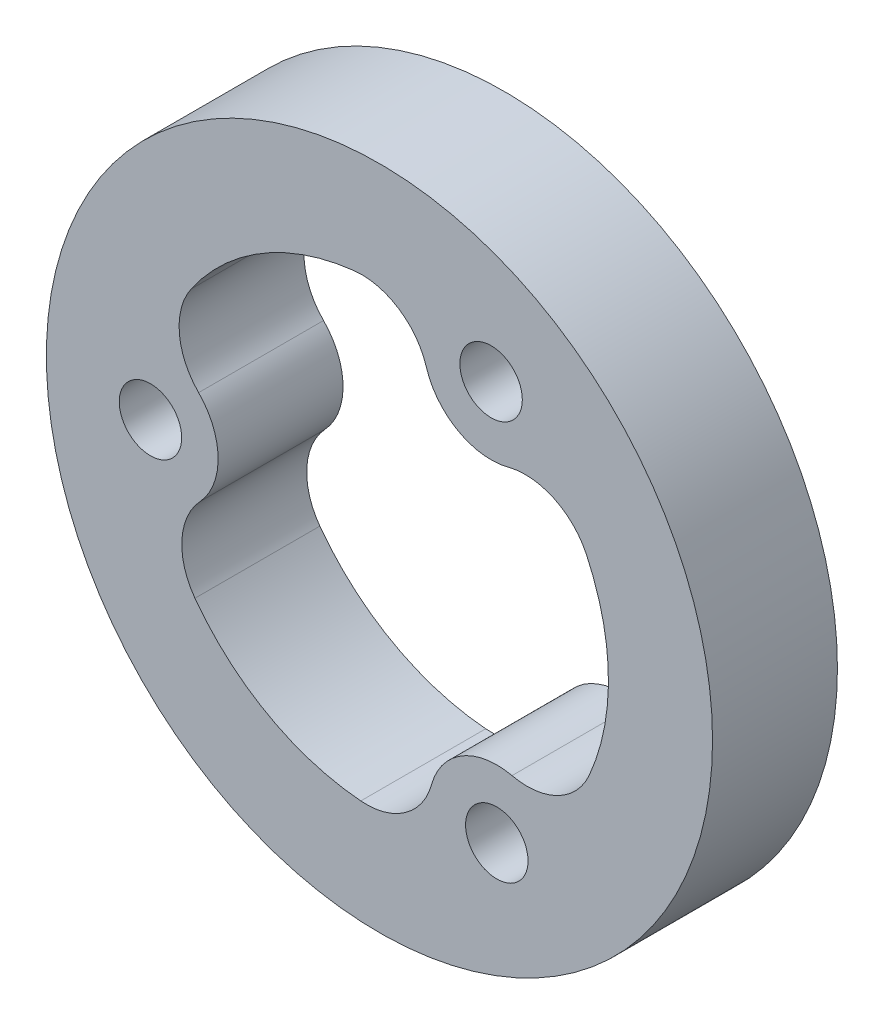
from build123d import *

# Parameters (mm, degrees)
ESQUISSE1_R        = 16
ESQUISSE1_R_2      = 1.5
BOSS_EXTRU_1_DEPTH = 6


with BuildPart() as part:
    # Esquisse1 → Boss.-Extru.1 (new body)
    with BuildSketch(Plane.XY):
        Circle(ESQUISSE1_R)
        with Locations((-10.998860664, -0.15831643)):
            Circle(ESQUISSE1_R_2, mode=Mode.SUBTRACT)
        with Locations((5.362324282, 9.604450963)):
            Circle(ESQUISSE1_R_2, mode=Mode.SUBTRACT)
        with Locations((5.636536382, -9.446134533)):
            Circle(ESQUISSE1_R_2, mode=Mode.SUBTRACT)
        with BuildLine():
            ThreePointArc((-8.621549645, -2.37436975), (-7.749197286, -0.111541121), (-8.68631658, 2.125242166))
            ThreePointArc((-8.68631658, 2.125242166), (-9.611487496, 4.126486074), (-9.046644834, 6.257652695))
            ThreePointArc((-9.046644834, 6.257652695), (-5.636536382, 9.446134533), (-1.211140708, 10.933121155))
            ThreePointArc((-1.211140708, 10.933121155), (0.932633718, 10.418194352), (2.254510301, 8.653665888))
            ThreePointArc((2.254510301, 8.653665888), (3.778001199, 6.766772269), (6.183671995, 6.459949741))
            ThreePointArc((6.183671995, 6.459949741), (8.379385516, 6.260549303), (9.942608619, 4.705797898))
            ThreePointArc((9.942608619, 4.705797898), (10.998860664, 0.15831643), (10.073931017, -4.417681957))
            ThreePointArc((10.073931017, -4.417681957), (8.556104111, -6.016781668), (6.367039345, -6.279296138))
            ThreePointArc((6.367039345, -6.279296138), (3.971196087, -6.655231148), (2.502644585, -8.585191907))
            ThreePointArc((2.502644585, -8.585191907), (1.23210198, -10.387035376), (-0.895963785, -10.963450593))
            ThreePointArc((-0.895963785, -10.963450593), (-5.362324282, -9.604450963), (-8.862790309, -6.515439198))
            ThreePointArc((-8.862790309, -6.515439198), (-9.488737829, -4.401412684), (-8.621549645, -2.37436975))
        make_face(mode=Mode.SUBTRACT)
    extrude(amount=BOSS_EXTRU_1_DEPTH)


solid = part.part
